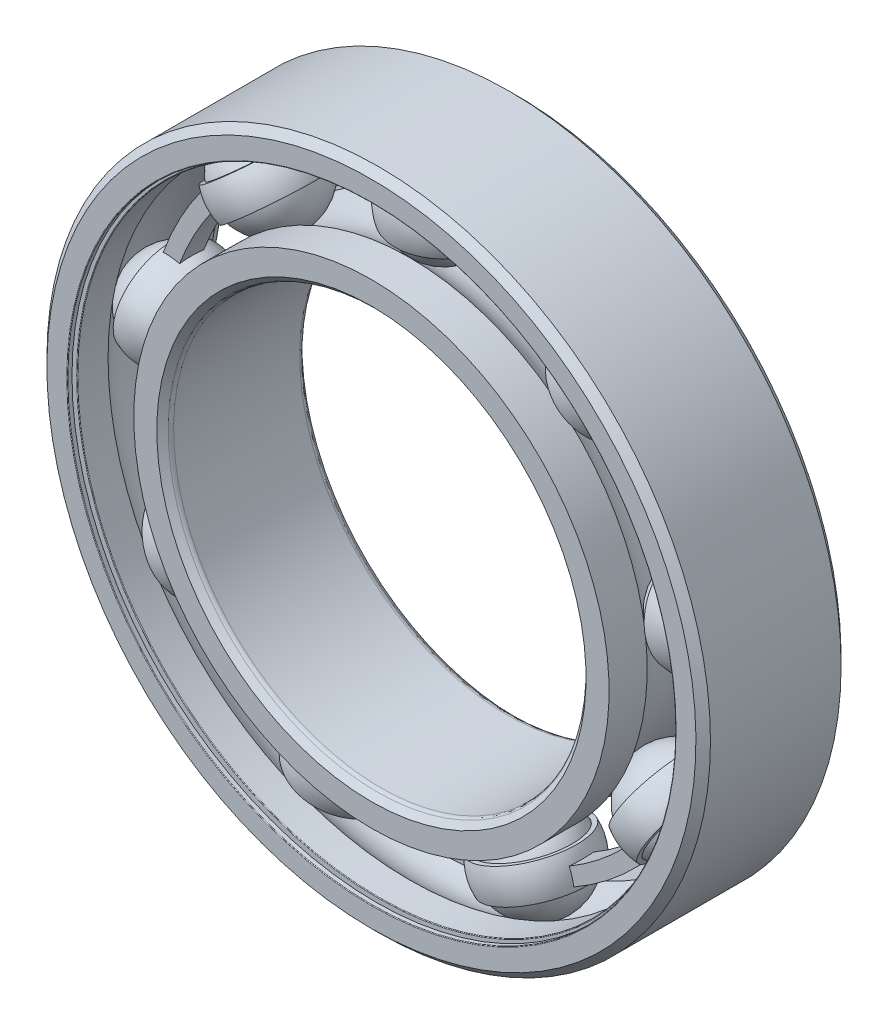
from build123d import *

# Parameters (mm, degrees)
BOSS_EXTRUDE1_DEPTH = 0.583333333
CIRPATTERN1_COUNT   = 9
CIRPATTERN2_COUNT   = 9
FILLET1_R           = 0.0315
FILLET2_R           = 0.2625


with BuildPart() as part:
    # Sketch3 → Revolve1 (revolve)
    with BuildSketch(Plane(origin=(0, 0, 0), x_dir=(0, 0, -1), z_dir=(1, 0, 0))):
        with BuildLine():
            Line((3.15, 16), (3.5, 15.65))
            Line((3.5, 15.65), (3.5, 14.538461538))
            Line((3.5, 14.538461538), (1.6625, 14.538461538))
            ThreePointArc((1.6625, 14.538461538), (0, 15.26512034), (-1.6625, 14.538461538))
            Line((-1.6625, 14.538461538), (-3.5, 14.538461538))
            Line((-3.5, 14.538461538), (-3.5, 15.65))
            Line((-3.5, 15.65), (-3.15, 16))
            Line((-3.15, 16), (3.15, 16))
        make_face()
    revolve(axis=Axis((0, 0, 3.5), (0, 0, -1)))

    # Sketch8 → Cut-Revolve1 (revolve, cut)
    with BuildSketch(Plane(origin=(0, 0, 0), x_dir=(0, 0, -1), z_dir=(1, 0, 0))):
        Polygon((-3.276, 14.538461538), (-3.15, 14.538461538), (-3.15, 15.025641026), (-3.276, 15.025641026), (-3.276, 14.664461538), (-3.5, 14.664461538), (-3.5, 14.538461538), align=None)
        Polygon((3.15, 14.538461538), (3.276, 14.538461538), (3.5, 14.538461538), (3.5, 14.664461538), (3.276, 14.664461538), (3.276, 15.025641026), (3.15, 15.025641026), align=None)
    revolve(axis=Axis((0, 0, 3.5), (0, 0, -1)), mode=Mode.SUBTRACT)

    # Fillet1
    fillet1_edges = [part.edges().sort_by_distance(p)[0] for p in [
        (0, -14.538461538, -3.15),
        (0, -14.664461538, -3.5),
        (0, -14.538461538, 3.15),
        (0, -14.664461538, 3.5),
    ]]
    fillet(fillet1_edges, radius=FILLET1_R)


with BuildPart() as body_2:
    # Sketch4 → Revolve2 (revolve)
    with BuildSketch(Plane(origin=(0, 0, 0), x_dir=(0, 0, -1), z_dir=(1, 0, 0))):
        with BuildLine():
            Line((-3.15, 10), (-3.5, 10.35))
            Line((-3.5, 10.35), (-3.5, 11.461538462))
            Line((-3.5, 11.461538462), (-1.6625, 11.461538462))
            ThreePointArc((-1.6625, 11.461538462), (0, 10.73487966), (1.6625, 11.461538462))
            Line((1.6625, 11.461538462), (3.5, 11.461538462))
            Line((3.5, 11.461538462), (3.5, 10.35))
            Line((3.5, 10.35), (3.15, 10))
            Line((3.15, 10), (-3.15, 10))
        make_face()
    revolve(axis=Axis((0, 0, 3.5), (0, 0, -1)))

    # Fillet2
    fillet2_edges = [body_2.edges().sort_by_distance(p)[0] for p in [
        (0, -10, -3.15),
        (0, -10, 3.15),
    ]]
    fillet(fillet2_edges, radius=FILLET2_R)


with BuildPart() as body_3:
    # Sketch5 → Revolve3 (revolve)
    with BuildSketch(Plane(origin=(0, 0, 0), x_dir=(0, 0, -1), z_dir=(1, 0, 0))):
        with BuildLine():
            Line((-2.26512034, 13), (2.26512034, 13))
            ThreePointArc((2.26512034, 13), (0, 15.26512034), (-2.26512034, 13))
        make_face()
    revolve(axis=Axis((0, 13, 2.26512034), (0, 0, -1)))


with BuildPart() as body_4:
    # Sketch6 → Revolve4 (revolve)
    with BuildSketch(Plane(origin=(0, 0, 0), x_dir=(0, 0, -1), z_dir=(1, 0, 0))):
        with BuildLine():
            Line((-2.130505616, 13.769230769), (-2.35875468, 13.769230769))
            ThreePointArc((-2.35875468, 13.769230769), (-2.472879212, 13), (-2.35875468, 12.230769231))
            Line((-2.35875468, 12.230769231), (-2.130505616, 12.230769231))
            ThreePointArc((-2.130505616, 12.230769231), (-2.26512034, 13), (-2.130505616, 13.769230769))
        make_face()
    revolve4 = revolve(axis=Axis((0, 16, 0), (0, -1, 0)))

    # Sketch7 → Boss-Extrude1 (add, symmetric)
    with BuildSketch(Plane.XY):
        with BuildLine():
            Line((8.45262429, 9.876899443), (8.952779573, 10.461331363))
            ThreePointArc((8.952779573, 10.461331363), (4.772170905, 12.915808176), (0, 13.769230769))
            Line((0, 13.769230769), (0, 13))
            ThreePointArc((0, 13), (4.505569178, 12.194254646), (8.45262429, 9.876899443))
        make_face()
    boss_extrude1 = extrude(amount=BOSS_EXTRUDE1_DEPTH, both=True)

    # CirPattern2: Revolve4, Boss-Extrude1 ×9 about axis
    cirpattern2_axis = Axis((0, 0, 3.5), (0, 0, -1))
    add([revolve4.rotate(cirpattern2_axis, i * 360 / CIRPATTERN2_COUNT) for i in range(1, CIRPATTERN2_COUNT)])
    add([boss_extrude1.rotate(cirpattern2_axis, i * 360 / CIRPATTERN2_COUNT) for i in range(1, CIRPATTERN2_COUNT)])


with BuildPart() as cirpattern1_1:
    # CirPattern1: pattern copy
    add(body_3.part.rotate(Axis((0, 0, 3.5), (0, 0, -1)), 1 * 360 / CIRPATTERN1_COUNT))


with BuildPart() as cirpattern1_2:
    # CirPattern1: pattern copy
    add(body_3.part.rotate(Axis((0, 0, 3.5), (0, 0, -1)), 2 * 360 / CIRPATTERN1_COUNT))


with BuildPart() as cirpattern1_3:
    # CirPattern1: pattern copy
    add(body_3.part.rotate(Axis((0, 0, 3.5), (0, 0, -1)), 3 * 360 / CIRPATTERN1_COUNT))


with BuildPart() as cirpattern1_4:
    # CirPattern1: pattern copy
    add(body_3.part.rotate(Axis((0, 0, 3.5), (0, 0, -1)), 4 * 360 / CIRPATTERN1_COUNT))


with BuildPart() as cirpattern1_5:
    # CirPattern1: pattern copy
    add(body_3.part.rotate(Axis((0, 0, 3.5), (0, 0, -1)), 5 * 360 / CIRPATTERN1_COUNT))


with BuildPart() as cirpattern1_6:
    # CirPattern1: pattern copy
    add(body_3.part.rotate(Axis((0, 0, 3.5), (0, 0, -1)), 6 * 360 / CIRPATTERN1_COUNT))


with BuildPart() as cirpattern1_7:
    # CirPattern1: pattern copy
    add(body_3.part.rotate(Axis((0, 0, 3.5), (0, 0, -1)), 7 * 360 / CIRPATTERN1_COUNT))


with BuildPart() as cirpattern1_8:
    # CirPattern1: pattern copy
    add(body_3.part.rotate(Axis((0, 0, 3.5), (0, 0, -1)), 8 * 360 / CIRPATTERN1_COUNT))


solid = Compound([part.part, body_2.part, body_3.part, body_4.part, cirpattern1_1.part, cirpattern1_2.part, cirpattern1_3.part, cirpattern1_4.part, cirpattern1_5.part, cirpattern1_6.part, cirpattern1_7.part, cirpattern1_8.part])
